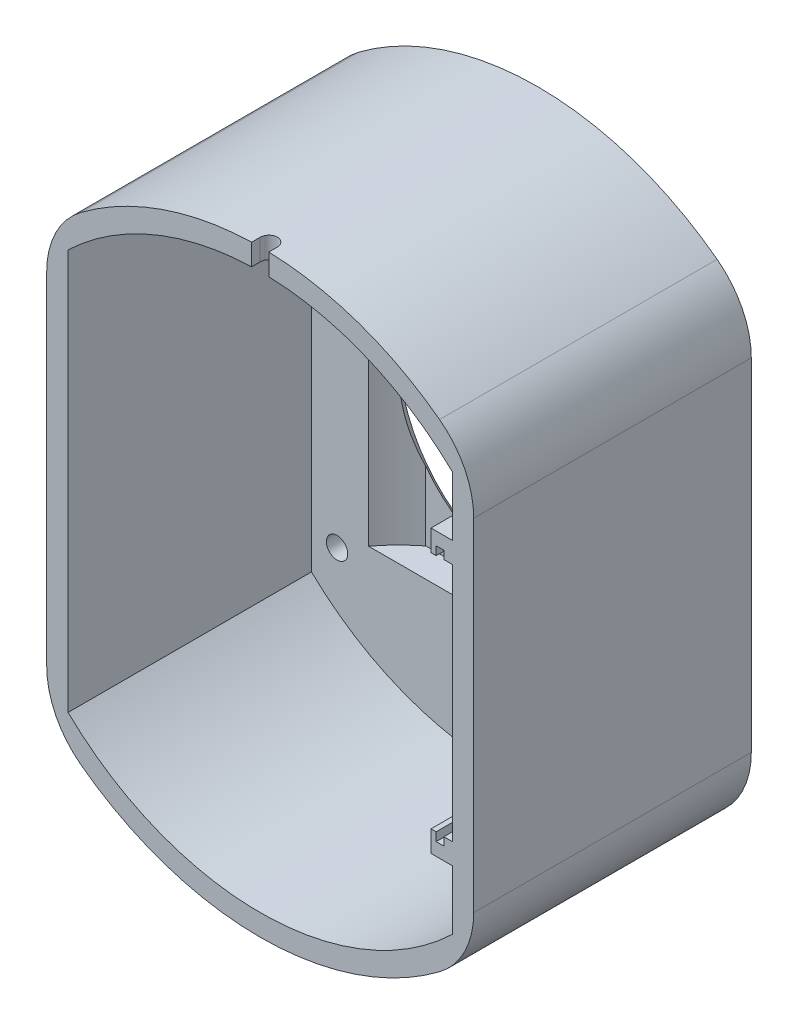
from build123d import *

# Parameters (mm, degrees)
EXTRUDE_2_DEPTH     = 65
SKETCH_1_3_R        = 2.5
BOSS_EXTRUDE1_DEPTH = 8
FILLET1_R           = 20
CHAMFER3_SIZE       = 5
BOSS_EXTRUDE3_DEPTH = 10
BOSS_EXTRUDE4_START = -45
BOSS_EXTRUDE4_DEPTH = 10
CUT_EXTRUDE2_DEPTH  = 108.819293264
SKETCH5_4_R         = 1.1
CUT_EXTRUDE3_DEPTH  = 68
CUT_EXTRUDE4_DEPTH  = 35
CHAMFER4_SIZE       = 2


with BuildPart() as part:
    # Эскиз1 → Extrude 2 (new body)
    with BuildSketch(Plane.XY):
        with BuildLine():
            ThreePointArc((-50, -48.989794856), (0, -70), (50, -48.989794856))
            Line((50, -48.989794856), (50, 48.989794856))
            ThreePointArc((50, 48.989794856), (0, 70), (-50, 48.989794856))
            Line((-50, 48.989794856), (-50, -48.989794856))
        make_face()
        with BuildLine():
            Line((45, -29.057462995), (45, -46.904157598))
            ThreePointArc((45, -46.904157598), (37.452737255, -53.125252678), (29.057462995, -58.143476369))
            ThreePointArc((29.057462995, -58.143476369), (0, -65), (-29.057462995, -58.143476369))
            ThreePointArc((-29.057462995, -58.143476369), (-37.452737255, -53.125252678), (-45, -46.904157598))
            Line((-45, -46.904157598), (-45, -29.057462995))
            Line((-45, -29.057462995), (-45, 29.057462995))
            Line((-45, 29.057462995), (-45, 46.904157598))
            ThreePointArc((-45, 46.904157598), (-37.452737255, 53.125252678), (-29.057462995, 58.143476369))
            ThreePointArc((-29.057462995, 58.143476369), (0, 65), (29.057462995, 58.143476369))
            ThreePointArc((29.057462995, 58.143476369), (37.452737255, 53.125252678), (45, 46.904157598))
            Line((45, 46.904157598), (45, 29.057462995))
            Line((45, 29.057462995), (45, -29.057462995))
        make_face(mode=Mode.SUBTRACT)
    extrude(amount=EXTRUDE_2_DEPTH)

    # Эскиз1<3> → Boss-Extrude1 (add)
    with BuildSketch(Plane.XY):
        with BuildLine():
            Line((45, -46.904157598), (45, 46.904157598))
            ThreePointArc((45, 46.904157598), (0, 65), (-45, 46.904157598))
            Line((-45, 46.904157598), (-45, -46.904157598))
            ThreePointArc((-45, -46.904157598), (0, -65), (45, -46.904157598))
        make_face()
        with Locations((39, -39)):
            Circle(SKETCH_1_3_R, mode=Mode.SUBTRACT)
        with BuildLine():
            Line((27.5, 0.1), (27.5, -0.1))
            ThreePointArc((27.5, -0.1), (19.474725805, -19.474725805), (0.1, -27.5))
            Line((0.1, -27.5), (-0.1, -27.5))
            ThreePointArc((-0.1, -27.5), (-19.474725805, -19.474725805), (-27.5, -0.1))
            Line((-27.5, -0.1), (-27.5, 0.1))
            ThreePointArc((-27.5, 0.1), (-19.474725805, 19.474725805), (-0.1, 27.5))
            Line((-0.1, 27.5), (0.1, 27.5))
            ThreePointArc((0.1, 27.5), (19.474725805, 19.474725805), (27.5, 0.1))
        make_face(mode=Mode.SUBTRACT)
        with Locations((-39, -39)):
            Circle(SKETCH_1_3_R, mode=Mode.SUBTRACT)
        with Locations((-39, 39)):
            Circle(SKETCH_1_3_R, mode=Mode.SUBTRACT)
        with Locations((39, 39)):
            Circle(SKETCH_1_3_R, mode=Mode.SUBTRACT)
    extrude(amount=BOSS_EXTRUDE1_DEPTH)

    # Fillet1
    fillet1_edges = [part.edges().sort_by_distance(p)[0] for p in [
        (50, -48.989794856, 32.5),
        (-50, -48.989794856, 32.5),
        (-50, 48.989794856, 32.5),
        (50, 48.989794856, 32.5),
    ]]
    fillet(fillet1_edges, radius=FILLET1_R)

    # Chamfer3
    chamfer3_edges = [part.edges().sort_by_distance(p)[0] for p in [
        (27.5, 0, 0),
        (19.474725805, 19.474725805, 0),
        (19.474725805, -19.474725805, 0),
        (0, 27.5, 0),
        (0, -27.5, 0),
        (-19.474725805, 19.474725805, 0),
        (-19.474725805, -19.474725805, 0),
        (-27.5, 0, 0),
    ]]
    chamfer(chamfer3_edges, length=CHAMFER3_SIZE)

    # Sketch3 → Boss-Extrude3 (add)
    with BuildSketch(Plane.XY.offset(65)):
        Polygon((41.2, -30), (41.2, -28), (40, -28), (40, -33), (45, -33), (45, -28.104490543), (43, -28.104490543), (43, -30), align=None)
        Polygon((45, 28.104490543), (45, 33), (40, 33), (40, 28), (41.2, 28), (41.2, 30), (43, 30), (43, 28.104490543), align=None)
    extrude(amount=-BOSS_EXTRUDE3_DEPTH)

    # Sketch3_2 → Boss-Extrude4 (add)
    with BuildSketch(Plane.XY.offset(65).offset(BOSS_EXTRUDE4_START)):
        Polygon((41.2, -30), (41.2, -28), (40, -28), (40, -33), (45, -33), (45, -28.104490543), (43, -28.104490543), (43, -30), align=None)
        Polygon((45, 28.104490543), (45, 33), (40, 33), (40, 28), (41.2, 28), (41.2, 30), (43, 30), (43, 28.104490543), align=None)
    extrude(amount=BOSS_EXTRUDE4_DEPTH)

    # Sketch5 → Cut-Extrude2 (cut, through all)
    with BuildSketch(Plane(origin=(0, 0, 0), x_dir=(1, 0, 0), z_dir=(0, 1, 0))):
        with BuildLine():
            ThreePointArc((2, -63), (0, -61), (-2, -63))
            Line((-2, -63), (-2, -65))
            Line((-2, -65), (2, -65))
            Line((2, -65), (2, -63))
        make_face()
    extrude(amount=CUT_EXTRUDE2_DEPTH, mode=Mode.SUBTRACT)

    # Sketch5_4 → Cut-Extrude3 (cut)
    with BuildSketch(Plane(origin=(0, 0, 0), x_dir=(1, 0, 0), z_dir=(0, 1, 0))):
        with Locations((5, -55)):
            Circle(SKETCH5_4_R)
        with Locations((-5, -55)):
            Circle(SKETCH5_4_R)
    extrude(amount=CUT_EXTRUDE3_DEPTH, mode=Mode.SUBTRACT)

    # Sketch6 → Cut-Extrude4 (cut, symmetric)
    with BuildSketch(Plane(origin=(0, 0, 0), x_dir=(1, 0, 0), z_dir=(0, 1, 0))):
        with BuildLine():
            Line((25, -1.25), (-25, -1.25))
            ThreePointArc((-25, -1.25), (-28.522145397, -4.427776683), (-31.643522244, -8))
            Line((-31.643522244, -8), (31.643522244, -8))
            ThreePointArc((31.643522244, -8), (28.522145397, -4.427776683), (25, -1.25))
        make_face()
    extrude(amount=CUT_EXTRUDE4_DEPTH, both=True, mode=Mode.SUBTRACT)

    # Chamfer4
    chamfer4_edges = [part.edges().sort_by_distance(p)[0] for p in [
        (36.5, 39, 0),
        (-41.5, 39, 0),
        (-41.5, -39, 0),
        (36.5, -39, 0),
    ]]
    chamfer(chamfer4_edges, length=CHAMFER4_SIZE)


solid = part.part
